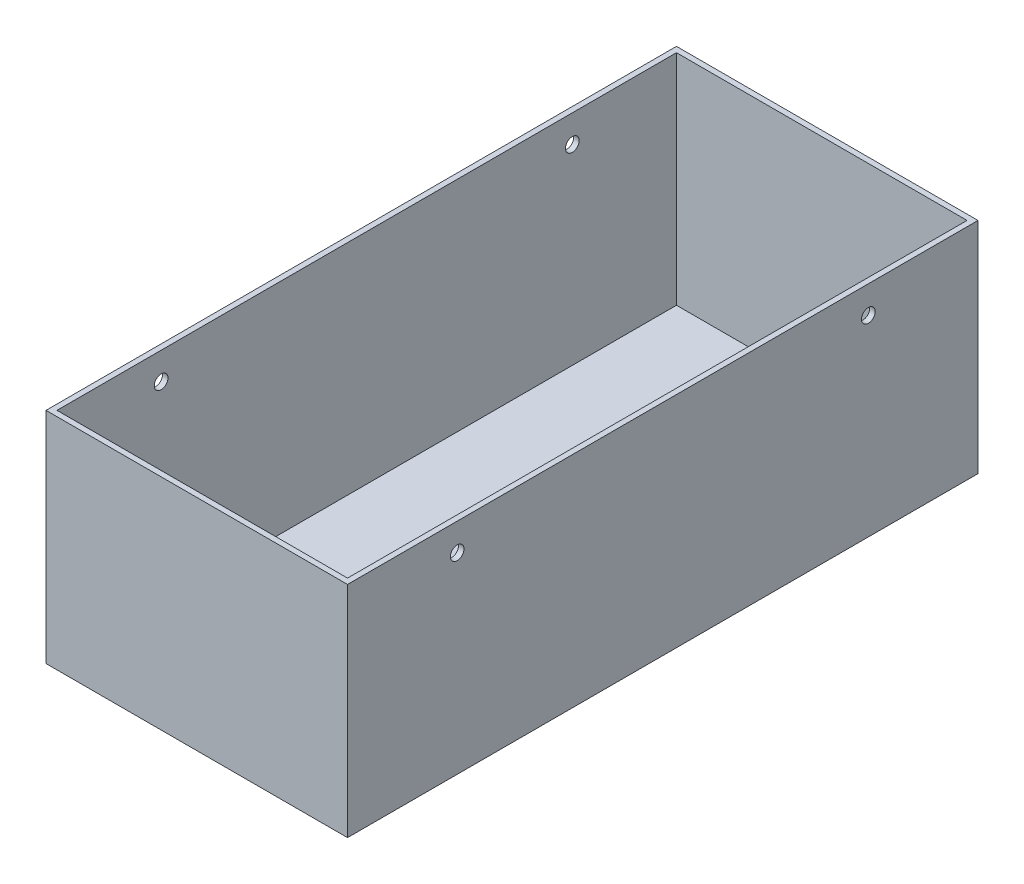
from build123d import *

# Parameters (mm, degrees)
SKETCH4_W           = 110
SKETCH4_H           = 230
BOSS_EXTRUDE3_DEPTH = 80
SKETCH5_W           = 106
SKETCH5_H           = 113
CUT_EXTRUDE2_DEPTH  = 79.8
SKETCH6_R           = 2.5
CUT_EXTRUDE3_DEPTH  = 130


with BuildPart() as part:
    # Sketch4 → Boss-Extrude3 (new body)
    with BuildSketch(Plane(origin=(0, 0, 0), x_dir=(1, 0, 0), z_dir=(0, 1, 0))):
        with Locations((117.5995229, 83.46665824)):
            Rectangle(SKETCH4_W, SKETCH4_H)
    extrude(amount=BOSS_EXTRUDE3_DEPTH)

    # Sketch5 → Cut-Extrude2 (cut)
    with BuildSketch(Plane(origin=(0, 80, 0), x_dir=(1, 0, 0), z_dir=(0, 1, 0))):
        with Locations((117.5995229, 139.96665824)):
            Rectangle(SKETCH5_W, SKETCH5_H)
        with Locations((117.5995229, 26.96665824)):
            Rectangle(SKETCH5_W, SKETCH5_H)
    extrude(amount=-CUT_EXTRUDE2_DEPTH, mode=Mode.SUBTRACT)

    # Sketch6 → Cut-Extrude3 (cut)
    with BuildSketch(Plane.ZY.offset(-62.5995229)):
        with Locations((-158.46665824, 70)):
            Circle(SKETCH6_R)
        with Locations((-8.46665824, 70)):
            Circle(SKETCH6_R)
    extrude(amount=-CUT_EXTRUDE3_DEPTH, mode=Mode.SUBTRACT)


solid = part.part
